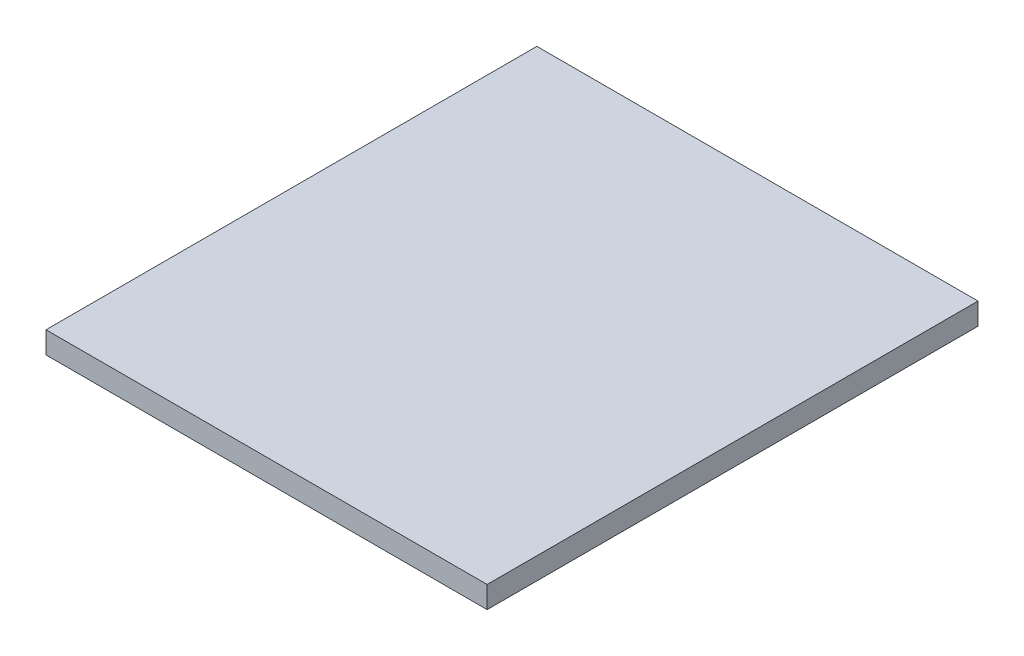
from build123d import *

# Parameters (mm, degrees)
SKETCH1_W           = 20.22
SKETCH1_H           = 22.5
BOSS_EXTRUDE1_DEPTH = 1


with BuildPart() as part:
    # Sketch1 → Boss-Extrude1 (new body)
    with BuildSketch(Plane(origin=(0, 0, 0), x_dir=(1, 0, 0), z_dir=(0, 1, 0))):
        with Locations((10.11, 11.25)):
            Rectangle(SKETCH1_W, SKETCH1_H)
    extrude(amount=BOSS_EXTRUDE1_DEPTH)


solid = part.part
